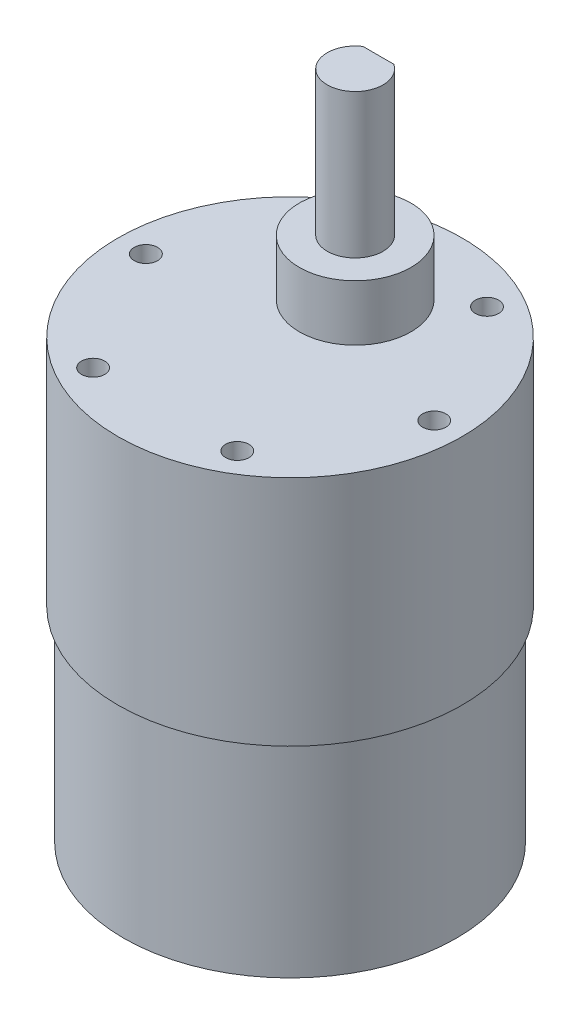
from build123d import *

# Parameters (mm, degrees)
SKETCH1_R                       = 18.499999957
BOSS_EXTRUDE1_DEPTH             = 25.000000038
SKETCH2_R                       = 5.999999938
BOSS_EXTRUDE2_DEPTH             = 5.999999938
BOSS_EXTRUDE3_DEPTH             = 15.499999988
BOSS_EXTRUDE4_DEPTH             = 5.999999938
TAP_DRILL_FOR_M3X0_5_TAP1_D     = 2.5
TAP_DRILL_FOR_M3X0_5_TAP1_DEPTH = 3.499993
TAP_DRILL_FOR_M3X0_5_TAP1_TIP   = 0.751075774
SKETCH7_R                       = 17.900000014
BOSS_EXTRUDE5_DEPTH             = 21.999999942


with BuildPart() as part:
    # Sketch1 → Boss-Extrude1 (new body)
    with BuildSketch(Plane(origin=(0, 0, 0), x_dir=(1, 0, 0), z_dir=(0, 1, 0))):
        Circle(SKETCH1_R)
    extrude(amount=BOSS_EXTRUDE1_DEPTH)

    # Sketch2 → Boss-Extrude2 (add)
    with BuildSketch(Plane(origin=(0, 25.000000038, 0), x_dir=(1, 0, 0), z_dir=(0, 1, 0))):
        with Locations((0, 6.99999997)):
            Circle(SKETCH2_R)
    extrude(amount=BOSS_EXTRUDE2_DEPTH)

    # Sketch3 → Boss-Extrude3 (add)
    with BuildSketch(Plane(origin=(0, 30.999999976, 0), x_dir=(1, 0, 0), z_dir=(0, 1, 0))):
        with BuildLine():
            Line((1.658312218, 9.50000005), (-1.658312218, 9.50000005))
            ThreePointArc((-1.658312218, 9.50000005), (0, 4.000000001), (1.658312218, 9.50000005))
        make_face()
    extrude(amount=BOSS_EXTRUDE3_DEPTH)

    # Sketch3_3 → Boss-Extrude4 (add)
    with BuildSketch(Plane(origin=(0, 30.999999976, 0), x_dir=(1, 0, 0), z_dir=(0, 1, 0))):
        with BuildLine():
            ThreePointArc((1.658312218, 9.50000005), (0, 9.999999939), (-1.658312218, 9.50000005))
            Line((-1.658312218, 9.50000005), (1.658312218, 9.50000005))
        make_face()
    extrude(amount=BOSS_EXTRUDE4_DEPTH)

    # Tap Drill for M3x0.5 Tap1
    with Locations(Plane(origin=(0, 25.000000038, 0), x_dir=(1, 0, 0), z_dir=(0, 1, 0))):
        with Locations((-15.499999988, 0), (-7.749999994, 13.423393748), (7.749999994, 13.423393748), (15.499999988, 0), (7.749999994, -13.423393748), (-7.749999994, -13.423393748)):
            Hole(TAP_DRILL_FOR_M3X0_5_TAP1_D / 2, depth=TAP_DRILL_FOR_M3X0_5_TAP1_DEPTH)
            with Locations((0, 0, -(TAP_DRILL_FOR_M3X0_5_TAP1_DEPTH + TAP_DRILL_FOR_M3X0_5_TAP1_TIP / 2))):  # 118° drill point
                Cone(0, TAP_DRILL_FOR_M3X0_5_TAP1_D / 2, TAP_DRILL_FOR_M3X0_5_TAP1_TIP, mode=Mode.SUBTRACT)

    # Sketch7 → Boss-Extrude5 (add)
    with BuildSketch(Plane.XZ):
        Circle(SKETCH7_R)
    extrude(amount=BOSS_EXTRUDE5_DEPTH)


solid = part.part
